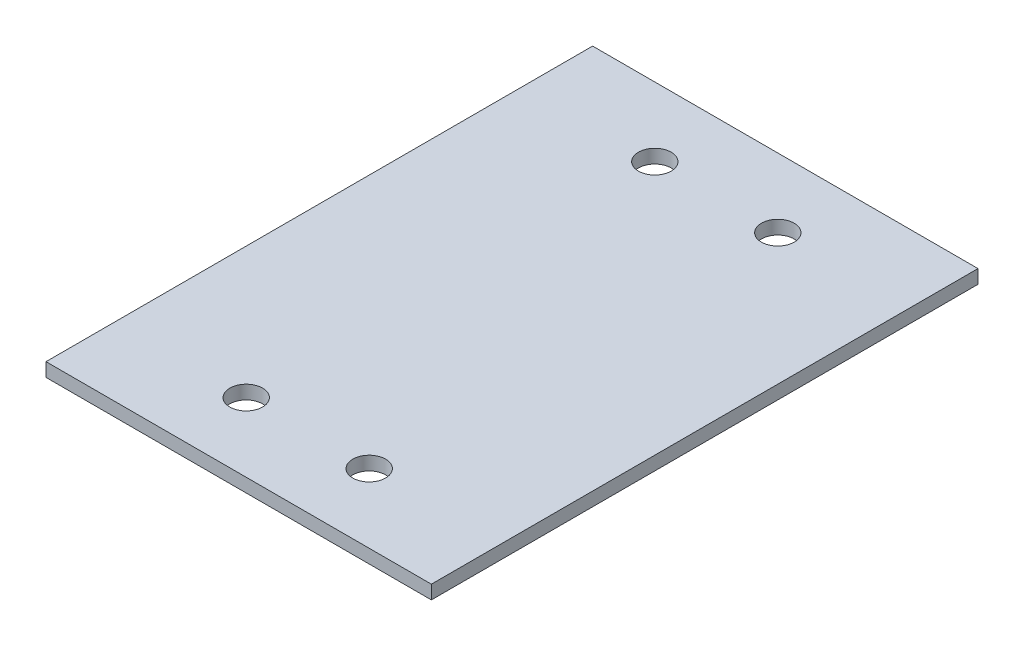
from build123d import *

# Parameters (mm, degrees)
SKETCH1_W           = 141
SKETCH1_H           = 200
SKETCH1_R           = 6
BOSS_EXTRUDE1_DEPTH = 5


with BuildPart() as part:
    # Sketch1 → Boss-Extrude1 (new body)
    with BuildSketch(Plane(origin=(0, 0, 0), x_dir=(1, 0, 0), z_dir=(0, 1, 0))):
        Rectangle(SKETCH1_W, SKETCH1_H)
        with Locations((-22.5, 74.75)):
            Circle(SKETCH1_R, mode=Mode.SUBTRACT)
        with Locations((22.5, 74.75)):
            Circle(SKETCH1_R, mode=Mode.SUBTRACT)
        with Locations((-22.5, -74.75)):
            Circle(SKETCH1_R, mode=Mode.SUBTRACT)
        with Locations((22.5, -74.75)):
            Circle(SKETCH1_R, mode=Mode.SUBTRACT)
    extrude(amount=BOSS_EXTRUDE1_DEPTH)


solid = part.part
